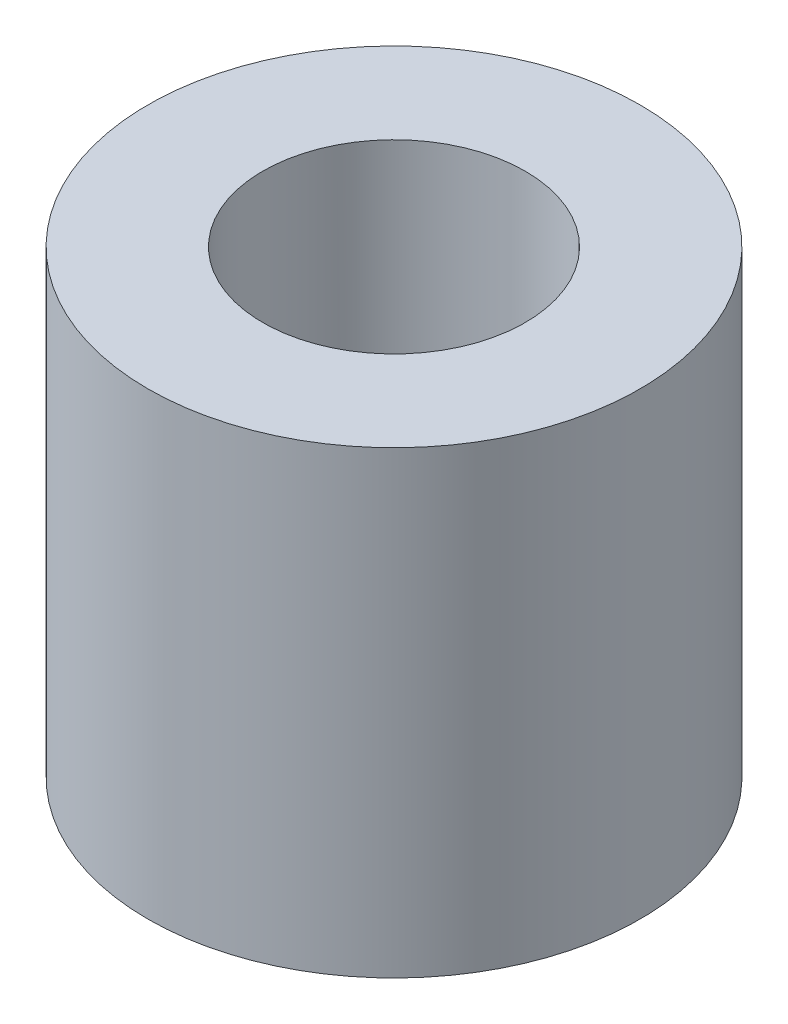
from build123d import *

# Parameters (mm, degrees)
SKETCH1_R      = 7.5
EXTRUDE1_DEPTH = 14


with BuildPart() as part:
    # Sketch1 → Extrude1 (new body)
    with BuildSketch(Plane(origin=(0, 0, 0), x_dir=(1, 0, 0), z_dir=(0, 1, 0))):
        with Locations(Location((0, 0, 0), (0, 0, 270))):  # turned: the seam where the file's is
            Circle(SKETCH1_R)
    extrude(amount=EXTRUDE1_DEPTH)

    # Sketch2 → Cut-Revolve1 (revolve, cut)
    with BuildSketch(Plane.XY, mode=Mode.PRIVATE) as cut_revolve1_sk:
        Polygon((0, 14), (4, 14), (4, 4), (0, 1.690598923), align=None)
    revolve(cut_revolve1_sk.sketch.rotate(Axis((0, 0, 0), (0, 1, 0)), 270), axis=Axis((0, 0, 0), (0, 1, 0)), mode=Mode.SUBTRACT)  # turned: the seam where the file's is


solid = part.part
